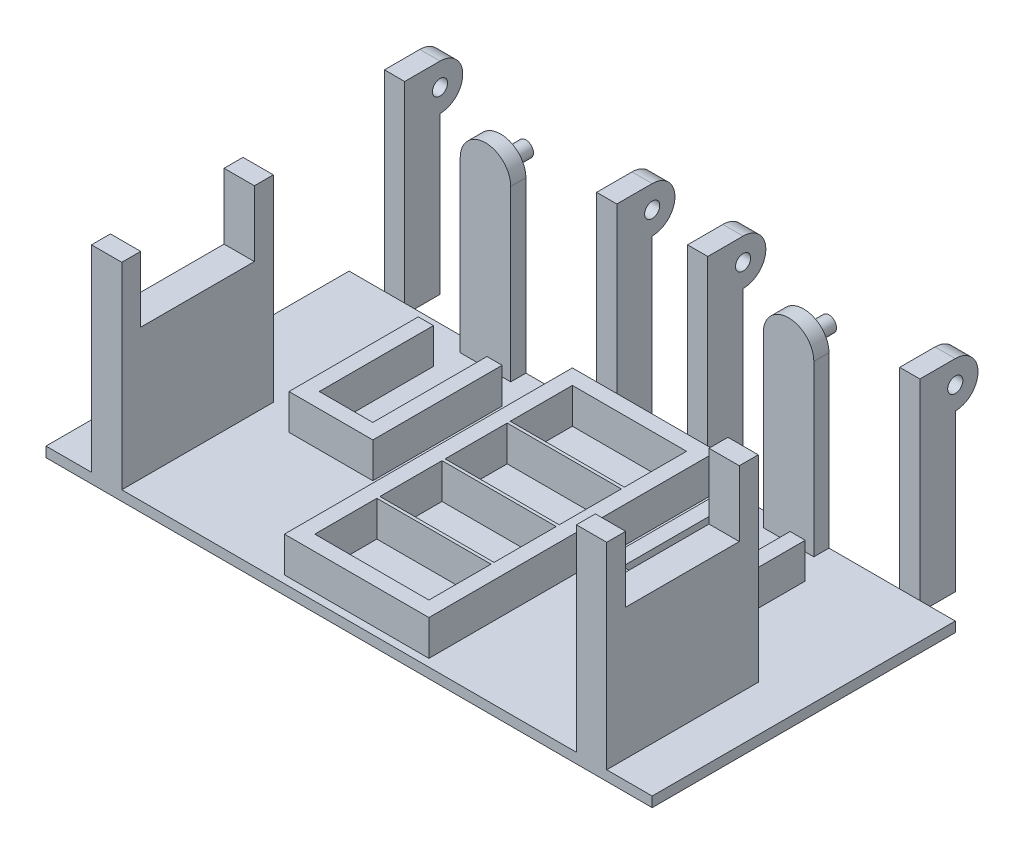
from build123d import *

# Parameters (mm, degrees)
BOSS_EXTRUDE1_DEPTH   = 9
BOSS_EXTRUDE1_2_DEPTH = 9
SKETCH1_3_W           = 6
SKETCH1_3_H           = 30
BOSS_EXTRUDE2_DEPTH   = 28
BOSS_EXTRUDE2_2_DEPTH = 28
SKETCH1_4_W           = 4
SKETCH1_4_H           = 7
BOSS_EXTRUDE3_DEPTH   = 40
BOSS_EXTRUDE3_2_DEPTH = 40
BOSS_EXTRUDE3_3_DEPTH = 40
BOSS_EXTRUDE3_4_DEPTH = 40
SKETCH1_5_W           = 10
SKETCH1_5_H           = 3
BOSS_EXTRUDE4_DEPTH   = 35.5
BOSS_EXTRUDE4_2_DEPTH = 35.5
SKETCH1_6_W           = 120
SKETCH1_6_H           = 60
BOSS_EXTRUDE5_DEPTH   = 2
SKETCH1_8_W           = 28.6
SKETCH1_8_H           = 57
SKETCH1_8_W_2         = 22.6
SKETCH1_8_H_2         = 51
BOSS_EXTRUDE6_DEPTH   = 9
SKETCH1_9_W           = 22.6
SKETCH1_9_H           = 0.6
BOSS_EXTRUDE7_DEPTH   = 9
SKETCH2_W             = 6
SKETCH2_H             = 3.75
BOSS_EXTRUDE8_DEPTH   = 13
BOSS_EXTRUDE9_DEPTH   = 3
SKETCH3_5_R           = 1.5
BOSS_EXTRUDE11_DEPTH  = 8
SKETCH4_R             = 4.5
SKETCH4_R_2           = 1.5
BOSS_EXTRUDE13_DEPTH  = 4
SKETCH4_4_R           = 1.5
CUT_EXTRUDE2_DEPTH    = 4
SKETCH5_R             = 4.5
SKETCH5_R_2           = 1.5
BOSS_EXTRUDE14_DEPTH  = 4
SKETCH5_2_R           = 1.5
CUT_EXTRUDE3_DEPTH    = 4
SKETCH7_R             = 4.5
SKETCH7_R_2           = 1.5
BOSS_EXTRUDE15_DEPTH  = 4
SKETCH7_2_R           = 1.5
CUT_EXTRUDE4_DEPTH    = 4
SKETCH8_R             = 4.5
SKETCH8_R_2           = 1.5
BOSS_EXTRUDE16_DEPTH  = 4
SKETCH8_4_R           = 1.5
CUT_EXTRUDE5_DEPTH    = 4


with BuildPart() as part:
    # Sketch1 → Boss-Extrude1 (new body)
    with BuildSketch(Plane(origin=(0, 0, 0), x_dir=(1, 0, 0), z_dir=(0, 1, 0))):
        Polygon((24.7, -0.6), (24.7, 22), (21.7, 22), (21.7, -3.6), (38.3, -3.6), (38.3, 22), (35.3, 22), (35.3, -0.6), align=None)
    extrude(amount=BOSS_EXTRUDE1_DEPTH)



with BuildPart() as body_2:
    # Sketch1 → Boss-Extrude1 2 (new body)
    with BuildSketch(Plane(origin=(0, 0, 0), x_dir=(1, 0, 0), z_dir=(0, 1, 0))):
        Polygon((-35.3, 22), (-38.3, 22), (-38.3, -3.6), (-21.7, -3.6), (-21.7, 22), (-24.7, 22), (-24.7, -0.6), (-35.3, -0.6), align=None)
    extrude(amount=BOSS_EXTRUDE1_2_DEPTH)


with BuildPart() as body_3:
    # Sketch1_3 → Boss-Extrude2 (new body)
    with BuildSketch(Plane(origin=(0, 0, 0), x_dir=(1, 0, 0), z_dir=(0, 1, 0))):
        with Locations((-48, -15)):
            Rectangle(SKETCH1_3_W, SKETCH1_3_H)
    extrude(amount=BOSS_EXTRUDE2_DEPTH)


with BuildPart() as body_4:
    # Sketch1_3 → Boss-Extrude2 2 (new body)
    with BuildSketch(Plane(origin=(0, 0, 0), x_dir=(1, 0, 0), z_dir=(0, 1, 0))):
        with Locations((48, -15)):
            Rectangle(SKETCH1_3_W, SKETCH1_3_H)
    extrude(amount=BOSS_EXTRUDE2_2_DEPTH)


with BuildPart() as body_5:
    # Sketch1_4 → Boss-Extrude3 (new body)
    with BuildSketch(Plane(origin=(0, 0, 0), x_dir=(1, 0, 0), z_dir=(0, 1, 0))):
        with Locations((-51, 33.5)):
            Rectangle(SKETCH1_4_W, SKETCH1_4_H)
    extrude(amount=BOSS_EXTRUDE3_DEPTH)


with BuildPart() as body_6:
    # Sketch1_4 → Boss-Extrude3 2 (new body)
    with BuildSketch(Plane(origin=(0, 0, 0), x_dir=(1, 0, 0), z_dir=(0, 1, 0))):
        with Locations((-9, 33.5)):
            Rectangle(SKETCH1_4_W, SKETCH1_4_H)
    extrude(amount=BOSS_EXTRUDE3_2_DEPTH)


with BuildPart() as body_7:
    # Sketch1_4 → Boss-Extrude3 3 (new body)
    with BuildSketch(Plane(origin=(0, 0, 0), x_dir=(1, 0, 0), z_dir=(0, 1, 0))):
        with Locations((9, 33.5)):
            Rectangle(SKETCH1_4_W, SKETCH1_4_H)
    extrude(amount=BOSS_EXTRUDE3_3_DEPTH)


with BuildPart() as body_8:
    # Sketch1_4 → Boss-Extrude3 4 (new body)
    with BuildSketch(Plane(origin=(0, 0, 0), x_dir=(1, 0, 0), z_dir=(0, 1, 0))):
        with Locations((51, 33.5)):
            Rectangle(SKETCH1_4_W, SKETCH1_4_H)
    extrude(amount=BOSS_EXTRUDE3_4_DEPTH)


with BuildPart() as body_9:
    # Sketch1_5 → Boss-Extrude4 (new body)
    with BuildSketch(Plane(origin=(0, 0, 0), x_dir=(1, 0, 0), z_dir=(0, 1, 0))):
        with Locations((30, 28.5)):
            Rectangle(SKETCH1_5_W, SKETCH1_5_H)
    extrude(amount=BOSS_EXTRUDE4_DEPTH)


with BuildPart() as body_10:
    # Sketch1_5 → Boss-Extrude4 2 (new body)
    with BuildSketch(Plane(origin=(0, 0, 0), x_dir=(1, 0, 0), z_dir=(0, 1, 0))):
        with Locations((-30, 28.5)):
            Rectangle(SKETCH1_5_W, SKETCH1_5_H)
    extrude(amount=BOSS_EXTRUDE4_2_DEPTH)


with BuildPart() as part_1:
    add(part.part)

    add(body_2.part)  # Boss-Extrude5 merges body 2

    add(body_3.part)  # Boss-Extrude5 merges body 3

    add(body_4.part)  # Boss-Extrude5 merges body 4

    add(body_5.part)  # Boss-Extrude5 merges body 5

    add(body_6.part)  # Boss-Extrude5 merges body 6

    add(body_7.part)  # Boss-Extrude5 merges body 7

    add(body_8.part)  # Boss-Extrude5 merges body 8

    add(body_9.part)  # Boss-Extrude5 merges body 9

    add(body_10.part)  # Boss-Extrude5 merges body 10
    # Sketch1_6 → Boss-Extrude5 (add)
    with BuildSketch(Plane(origin=(0, 0, 0), x_dir=(1, 0, 0), z_dir=(0, 1, 0))):
        Rectangle(SKETCH1_6_W, SKETCH1_6_H)
    extrude(amount=BOSS_EXTRUDE5_DEPTH)

    # Sketch1_8 → Boss-Extrude6 (add)
    with BuildSketch(Plane(origin=(0, 0, 0), x_dir=(1, 0, 0), z_dir=(0, 1, 0))):
        Rectangle(SKETCH1_8_W, SKETCH1_8_H)
        Rectangle(SKETCH1_8_W_2, SKETCH1_8_H_2, mode=Mode.SUBTRACT)
    extrude(amount=BOSS_EXTRUDE6_DEPTH)

    # Sketch1_9 → Boss-Extrude7 (add)
    with BuildSketch(Plane(origin=(0, 0, 0), x_dir=(1, 0, 0), z_dir=(0, 1, 0))):
        with Locations((0, 12.9)):
            Rectangle(SKETCH1_9_W, SKETCH1_9_H)
        Rectangle(SKETCH1_9_W, SKETCH1_9_H)
        with Locations((0, -12.9)):
            Rectangle(SKETCH1_9_W, SKETCH1_9_H)
    extrude(amount=BOSS_EXTRUDE7_DEPTH)

    # Sketch2 → Boss-Extrude8 (add)
    with BuildSketch(Plane(origin=(0, 28, 0), x_dir=(1, 0, 0), z_dir=(0, 1, 0))):
        with Locations((-48, -1.875)):
            Rectangle(SKETCH2_W, SKETCH2_H)
        with Locations((-48, -28.125)):
            Rectangle(SKETCH2_W, SKETCH2_H)
        with Locations((48, -1.875)):
            Rectangle(SKETCH2_W, SKETCH2_H)
        with Locations((48, -28.125)):
            Rectangle(SKETCH2_W, SKETCH2_H)
    extrude(amount=BOSS_EXTRUDE8_DEPTH)

    # Sketch3 → Boss-Extrude9 (add)
    with BuildSketch(Plane.XY.offset(-27)):
        with BuildLine():
            ThreePointArc((-31.5, 35.5), (-30, 37), (-28.5, 35.5))
            Line((-28.5, 35.5), (-25, 35.5))
            ThreePointArc((-25, 35.5), (-30, 40.5), (-35, 35.5))
            Line((-35, 35.5), (-31.5, 35.5))
        make_face()
        with BuildLine():
            ThreePointArc((28.5, 35.5), (30, 37), (31.5, 35.5))
            Line((31.5, 35.5), (35, 35.5))
            ThreePointArc((35, 35.5), (30, 40.5), (25, 35.5))
            Line((25, 35.5), (28.5, 35.5))
        make_face()
    extrude(amount=-BOSS_EXTRUDE9_DEPTH)

    # Sketch3_5 → Boss-Extrude11 (add)
    with BuildSketch(Plane.XY.offset(-27)):
        with Locations((-30, 35.5)):
            Circle(SKETCH3_5_R)
        with Locations((30, 35.5)):
            Circle(SKETCH3_5_R)
    extrude(amount=-BOSS_EXTRUDE11_DEPTH)

    # Sketch4 → Boss-Extrude13 (add)
    with BuildSketch(Plane.ZY.offset(53)):
        with Locations((-37, 35.5)):
            Circle(SKETCH4_R)
        with Locations((-37, 35.5)):
            Circle(SKETCH4_R_2, mode=Mode.SUBTRACT)
    extrude(amount=-BOSS_EXTRUDE13_DEPTH)

    # Sketch4_4 → Cut-Extrude2 (cut)
    with BuildSketch(Plane.ZY.offset(53)):
        with Locations((-37, 35.5)):
            Circle(SKETCH4_4_R)
    extrude(amount=-CUT_EXTRUDE2_DEPTH, mode=Mode.SUBTRACT)

    # Sketch5 → Boss-Extrude14 (add)
    with BuildSketch(Plane.ZY.offset(11)):
        with Locations((-37, 35.5)):
            Circle(SKETCH5_R)
        with Locations((-37, 35.5)):
            Circle(SKETCH5_R_2, mode=Mode.SUBTRACT)
    extrude(amount=-BOSS_EXTRUDE14_DEPTH)

    # Sketch5_2 → Cut-Extrude3 (cut)
    with BuildSketch(Plane.ZY.offset(11)):
        with Locations((-37, 35.5)):
            Circle(SKETCH5_2_R)
    extrude(amount=-CUT_EXTRUDE3_DEPTH, mode=Mode.SUBTRACT)

    # Sketch7 → Boss-Extrude15 (add)
    with BuildSketch(Plane.ZY.offset(-7)):
        with Locations((-37, 35.5)):
            Circle(SKETCH7_R)
        with Locations((-37, 35.5)):
            Circle(SKETCH7_R_2, mode=Mode.SUBTRACT)
    extrude(amount=-BOSS_EXTRUDE15_DEPTH)

    # Sketch7_2 → Cut-Extrude4 (cut)
    with BuildSketch(Plane.ZY.offset(-7)):
        with Locations((-37, 35.5)):
            Circle(SKETCH7_2_R)
    extrude(amount=-CUT_EXTRUDE4_DEPTH, mode=Mode.SUBTRACT)

    # Sketch8 → Boss-Extrude16 (add)
    with BuildSketch(Plane.ZY.offset(-49)):
        with Locations((-37, 35.5)):
            Circle(SKETCH8_R)
        with Locations((-37, 35.5)):
            Circle(SKETCH8_R_2, mode=Mode.SUBTRACT)
    extrude(amount=-BOSS_EXTRUDE16_DEPTH)

    # Sketch8_4 → Cut-Extrude5 (cut)
    with BuildSketch(Plane.ZY.offset(-49)):
        with Locations((-37, 35.5)):
            Circle(SKETCH8_4_R)
    extrude(amount=-CUT_EXTRUDE5_DEPTH, mode=Mode.SUBTRACT)


solid = part_1.part
